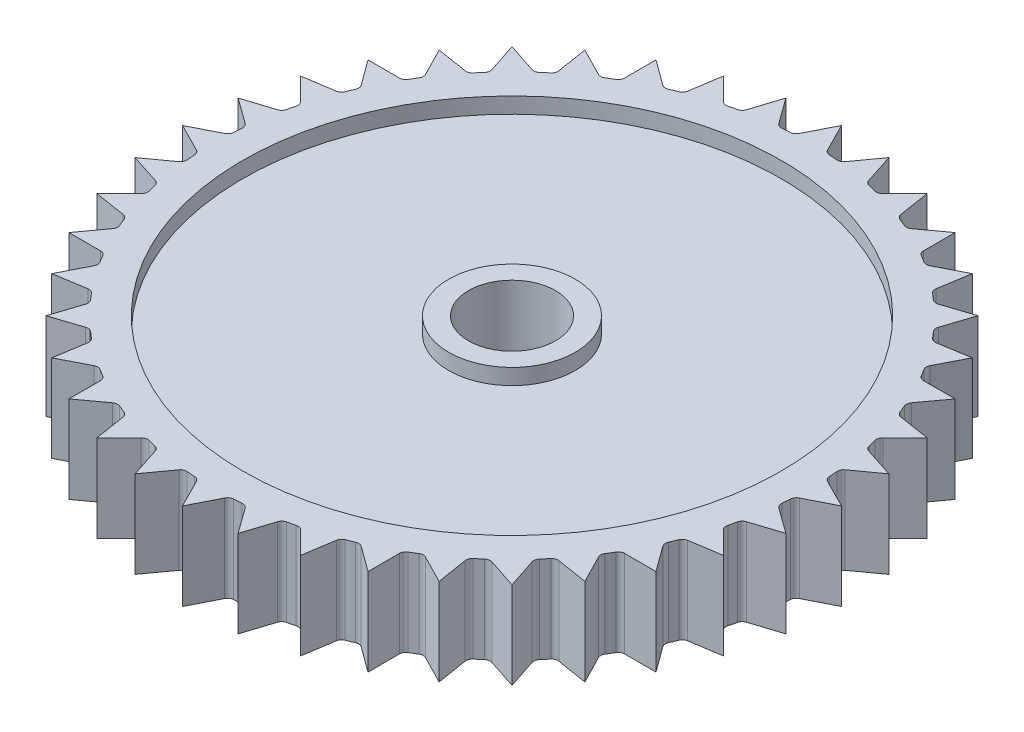
from build123d import *

# Parameters (mm, degrees)
BOSS_EXTRUDE1_DEPTH = 5.5
SKETCH2_R           = 2.75
CUT_EXTRUDE1_DEPTH  = 30.939308609
SKETCH2_3_R         = 17
SKETCH2_3_R_2       = 4
CUT_EXTRUDE2_DEPTH  = 1
CUT_EXTRUDE4_START  = -1
SKETCH4_R           = 17
SKETCH4_R_2         = 4
CUT_EXTRUDE4_DEPTH  = 1
BOSS_EXTRUDE2_DEPTH = 5.5


with BuildPart() as part:
    # Sketch1 → Boss-Extrude1 (new body)
    with BuildSketch(Plane(origin=(0, 0, 0), x_dir=(1, 0, 0), z_dir=(0, 1, 0))):
        with BuildLine():
            Line((0.896211504, 19.03861126), (0, 20.81))
            Line((0, 20.81), (-0.896211504, 19.03861126))
            ThreePointArc((-0.896211504, 19.03861126), (-1.032664638, 18.885431522), (-1.22710516, 18.820037538))
            ThreePointArc((-1.22710516, 18.820037538), (-1.479738545, 18.801860914), (-1.732105045, 18.780293185))
            ThreePointArc((-1.732105045, 18.780293185), (-1.934381554, 18.814464862), (-2.093117314, 18.94441273))
            Line((-2.093117314, 18.94441273), (-3.255401217, 20.553794368))
            Line((-3.255401217, 20.553794368), (-3.863472621, 18.664015995))
            ThreePointArc((-3.863472621, 18.664015995), (-3.9742832, 18.491376181), (-4.156099964, 18.396370106))
            ThreePointArc((-4.156099964, 18.396370106), (-4.402779562, 18.338896699), (-4.648665075, 18.278115686))
            ThreePointArc((-4.648665075, 18.278115686), (-4.853796853, 18.280223635), (-5.030906637, 18.383739885))
            Line((-5.030906637, 18.383739885), (-6.430643653, 19.791486104))
            Line((-6.430643653, 19.791486104), (-6.73560222, 17.829850715))
            ThreePointArc((-6.73560222, 17.829850715), (-6.81804172, 17.642001789), (-6.982757793, 17.519722989))
            ThreePointArc((-6.982757793, 17.519722989), (-7.217409534, 17.424367983), (-7.450759543, 17.325870317))
            ThreePointArc((-7.450759543, 17.325870317), (-7.653695565, 17.295862633), (-7.844818343, 17.370398353))
            Line((-7.844818343, 17.370398353), (-9.4475423, 18.541845768))
            Line((-9.4475423, 18.541845768), (-9.441878938, 16.556655335))
            ThreePointArc((-9.441878938, 16.556655335), (-9.493917424, 16.358222763), (-9.63747695, 16.211682147))
            ThreePointArc((-9.63747695, 16.211682147), (-9.854322931, 16.0807935), (-10.069391584, 15.947004519))
            ThreePointArc((-10.069391584, 15.947004519), (-10.26513489, 15.885620092), (-10.465564585, 15.929339964))
            Line((-10.465564585, 15.929339964), (-12.2318111, 16.835643653))
            Line((-12.2318111, 16.835643653), (-11.91566526, 14.875780153))
            ThreePointArc((-11.91566526, 14.875780153), (-11.936021374, 14.671650003), (-12.054889441, 14.504455887))
            ThreePointArc((-12.054889441, 14.504455887), (-12.248590192, 14.341256511), (-12.440081785, 14.175470545))
            ThreePointArc((-12.440081785, 14.175470545), (-12.623812527, 14.084220863), (-12.828613894, 14.096048358))
            Line((-12.828613894, 14.096048358), (-14.714892116, 14.714892116))
            Line((-14.714892116, 14.714892116), (-14.096048358, 12.828613894))
            ThreePointArc((-14.096048358, 12.828613894), (-14.084220863, 12.623812527), (-14.175470545, 12.440081785))
            ThreePointArc((-14.175470545, 12.440081785), (-14.341256511, 12.248590192), (-14.504455887, 12.054889441))
            ThreePointArc((-14.504455887, 12.054889441), (-14.671650003, 11.936021374), (-14.875780153, 11.91566526))
            Line((-14.875780153, 11.91566526), (-16.835643653, 12.2318111))
            Line((-16.835643653, 12.2318111), (-15.929339964, 10.465564585))
            ThreePointArc((-15.929339964, 10.465564585), (-15.885620092, 10.26513489), (-15.947004519, 10.069391584))
            ThreePointArc((-15.947004519, 10.069391584), (-16.0807935, 9.854322931), (-16.211682147, 9.63747695))
            ThreePointArc((-16.211682147, 9.63747695), (-16.358222763, 9.493917424), (-16.556655335, 9.441878938))
            Line((-16.556655335, 9.441878938), (-18.541845768, 9.4475423))
            Line((-18.541845768, 9.4475423), (-17.370398353, 7.844818343))
            ThreePointArc((-17.370398353, 7.844818343), (-17.295862633, 7.653695565), (-17.325870317, 7.450759543))
            ThreePointArc((-17.325870317, 7.450759543), (-17.424367983, 7.217409534), (-17.519722989, 6.982757793))
            ThreePointArc((-17.519722989, 6.982757793), (-17.642001789, 6.81804172), (-17.829850715, 6.73560222))
            Line((-17.829850715, 6.73560222), (-19.791486104, 6.430643653))
            Line((-19.791486104, 6.430643653), (-18.383739885, 5.030906637))
            ThreePointArc((-18.383739885, 5.030906637), (-18.280223635, 4.853796853), (-18.278115686, 4.648665075))
            ThreePointArc((-18.278115686, 4.648665075), (-18.338896699, 4.402779562), (-18.396370106, 4.156099964))
            ThreePointArc((-18.396370106, 4.156099964), (-18.491376181, 3.9742832), (-18.664015995, 3.863472621))
            Line((-18.664015995, 3.863472621), (-20.553794368, 3.255401217))
            Line((-20.553794368, 3.255401217), (-18.94441273, 2.093117314))
            ThreePointArc((-18.94441273, 2.093117314), (-18.814464862, 1.934381554), (-18.780293185, 1.732105045))
            ThreePointArc((-18.780293185, 1.732105045), (-18.801860914, 1.479738545), (-18.820037538, 1.22710516))
            ThreePointArc((-18.820037538, 1.22710516), (-18.885431522, 1.032664638), (-19.03861126, 0.896211504))
            Line((-19.03861126, 0.896211504), (-20.81, 0))
            Line((-20.81, 0), (-19.03861126, -0.896211504))
            ThreePointArc((-19.03861126, -0.896211504), (-18.885431522, -1.032664638), (-18.820037538, -1.22710516))
            ThreePointArc((-18.820037538, -1.22710516), (-18.801860914, -1.479738545), (-18.780293185, -1.732105045))
            ThreePointArc((-18.780293185, -1.732105045), (-18.814464862, -1.934381554), (-18.94441273, -2.093117314))
            Line((-18.94441273, -2.093117314), (-20.553794368, -3.255401217))
            Line((-20.553794368, -3.255401217), (-18.664015995, -3.863472621))
            ThreePointArc((-18.664015995, -3.863472621), (-18.491376181, -3.9742832), (-18.396370106, -4.156099964))
            ThreePointArc((-18.396370106, -4.156099964), (-18.338896699, -4.402779562), (-18.278115686, -4.648665075))
            ThreePointArc((-18.278115686, -4.648665075), (-18.280223635, -4.853796853), (-18.383739885, -5.030906637))
            Line((-18.383739885, -5.030906637), (-19.791486104, -6.430643653))
            Line((-19.791486104, -6.430643653), (-17.829850715, -6.73560222))
            ThreePointArc((-17.829850715, -6.73560222), (-17.642001789, -6.81804172), (-17.519722989, -6.982757793))
            ThreePointArc((-17.519722989, -6.982757793), (-17.424367983, -7.217409534), (-17.325870317, -7.450759543))
            ThreePointArc((-17.325870317, -7.450759543), (-17.295862633, -7.653695565), (-17.370398353, -7.844818343))
            Line((-17.370398353, -7.844818343), (-18.541845768, -9.4475423))
            Line((-18.541845768, -9.4475423), (-16.556655335, -9.441878938))
            ThreePointArc((-16.556655335, -9.441878938), (-16.358222763, -9.493917424), (-16.211682147, -9.63747695))
            ThreePointArc((-16.211682147, -9.63747695), (-16.0807935, -9.854322931), (-15.947004519, -10.069391584))
            ThreePointArc((-15.947004519, -10.069391584), (-15.885620092, -10.26513489), (-15.929339964, -10.465564585))
            Line((-15.929339964, -10.465564585), (-16.835643653, -12.2318111))
            Line((-16.835643653, -12.2318111), (-14.875780153, -11.91566526))
            ThreePointArc((-14.875780153, -11.91566526), (-14.671650003, -11.936021374), (-14.504455887, -12.054889441))
            ThreePointArc((-14.504455887, -12.054889441), (-14.341256511, -12.248590192), (-14.175470545, -12.440081785))
            ThreePointArc((-14.175470545, -12.440081785), (-14.084220863, -12.623812527), (-14.096048358, -12.828613894))
            Line((-14.096048358, -12.828613894), (-14.714892116, -14.714892116))
            Line((-14.714892116, -14.714892116), (-12.828613894, -14.096048358))
            ThreePointArc((-12.828613894, -14.096048358), (-12.623812527, -14.084220863), (-12.440081785, -14.175470545))
            ThreePointArc((-12.440081785, -14.175470545), (-12.248590192, -14.341256511), (-12.054889441, -14.504455887))
            ThreePointArc((-12.054889441, -14.504455887), (-11.936021374, -14.671650003), (-11.91566526, -14.875780153))
            Line((-11.91566526, -14.875780153), (-12.2318111, -16.835643653))
            Line((-12.2318111, -16.835643653), (-10.465564585, -15.929339964))
            ThreePointArc((-10.465564585, -15.929339964), (-10.26513489, -15.885620092), (-10.069391584, -15.947004519))
            ThreePointArc((-10.069391584, -15.947004519), (-9.854322931, -16.0807935), (-9.63747695, -16.211682147))
            ThreePointArc((-9.63747695, -16.211682147), (-9.493917424, -16.358222763), (-9.441878938, -16.556655335))
            Line((-9.441878938, -16.556655335), (-9.4475423, -18.541845768))
            Line((-9.4475423, -18.541845768), (-7.844818343, -17.370398353))
            ThreePointArc((-7.844818343, -17.370398353), (-7.653695565, -17.295862633), (-7.450759543, -17.325870317))
            ThreePointArc((-7.450759543, -17.325870317), (-7.217409534, -17.424367983), (-6.982757793, -17.519722989))
            ThreePointArc((-6.982757793, -17.519722989), (-6.81804172, -17.642001789), (-6.73560222, -17.829850715))
            Line((-6.73560222, -17.829850715), (-6.430643653, -19.791486104))
            Line((-6.430643653, -19.791486104), (-5.030906637, -18.383739885))
            ThreePointArc((-5.030906637, -18.383739885), (-4.853796853, -18.280223635), (-4.648665075, -18.278115686))
            ThreePointArc((-4.648665075, -18.278115686), (-4.402779562, -18.338896699), (-4.156099964, -18.396370106))
            ThreePointArc((-4.156099964, -18.396370106), (-3.9742832, -18.491376181), (-3.863472621, -18.664015995))
            Line((-3.863472621, -18.664015995), (-3.255401217, -20.553794368))
            Line((-3.255401217, -20.553794368), (-2.093117314, -18.94441273))
            ThreePointArc((-2.093117314, -18.94441273), (-1.934381554, -18.814464862), (-1.732105045, -18.780293185))
            ThreePointArc((-1.732105045, -18.780293185), (-1.479738545, -18.801860914), (-1.22710516, -18.820037538))
            ThreePointArc((-1.22710516, -18.820037538), (-1.032664638, -18.885431522), (-0.896211504, -19.03861126))
            Line((-0.896211504, -19.03861126), (0, -20.81))
            Line((0, -20.81), (0.896211504, -19.03861126))
            ThreePointArc((0.896211504, -19.03861126), (1.032664638, -18.885431522), (1.22710516, -18.820037538))
            ThreePointArc((1.22710516, -18.820037538), (1.479738545, -18.801860914), (1.732105045, -18.780293185))
            ThreePointArc((1.732105045, -18.780293185), (1.934381554, -18.814464862), (2.093117314, -18.94441273))
            Line((2.093117314, -18.94441273), (3.255401217, -20.553794368))
            Line((3.255401217, -20.553794368), (3.863472621, -18.664015995))
            ThreePointArc((3.863472621, -18.664015995), (3.9742832, -18.491376181), (4.156099964, -18.396370106))
            ThreePointArc((4.156099964, -18.396370106), (4.402779562, -18.338896699), (4.648665075, -18.278115686))
            ThreePointArc((4.648665075, -18.278115686), (4.853796853, -18.280223635), (5.030906637, -18.383739885))
            Line((5.030906637, -18.383739885), (6.430643653, -19.791486104))
            Line((6.430643653, -19.791486104), (6.73560222, -17.829850715))
            ThreePointArc((6.73560222, -17.829850715), (6.81804172, -17.642001789), (6.982757793, -17.519722989))
            ThreePointArc((6.982757793, -17.519722989), (7.217409534, -17.424367983), (7.450759543, -17.325870317))
            ThreePointArc((7.450759543, -17.325870317), (7.653695565, -17.295862633), (7.844818343, -17.370398353))
            Line((7.844818343, -17.370398353), (9.4475423, -18.541845768))
            Line((9.4475423, -18.541845768), (9.441878938, -16.556655335))
            ThreePointArc((9.441878938, -16.556655335), (9.493917424, -16.358222763), (9.63747695, -16.211682147))
            ThreePointArc((9.63747695, -16.211682147), (9.854322931, -16.0807935), (10.069391584, -15.947004519))
            ThreePointArc((10.069391584, -15.947004519), (10.26513489, -15.885620092), (10.465564585, -15.929339964))
            Line((10.465564585, -15.929339964), (12.2318111, -16.835643653))
            Line((12.2318111, -16.835643653), (11.91566526, -14.875780153))
            ThreePointArc((11.91566526, -14.875780153), (11.936021374, -14.671650003), (12.054889441, -14.504455887))
            ThreePointArc((12.054889441, -14.504455887), (12.248590192, -14.341256511), (12.440081785, -14.175470545))
            ThreePointArc((12.440081785, -14.175470545), (12.623812527, -14.084220863), (12.828613894, -14.096048358))
            Line((12.828613894, -14.096048358), (14.714892116, -14.714892116))
            Line((14.714892116, -14.714892116), (14.096048358, -12.828613894))
            ThreePointArc((14.096048358, -12.828613894), (14.084220863, -12.623812527), (14.175470545, -12.440081785))
            ThreePointArc((14.175470545, -12.440081785), (14.341256511, -12.248590192), (14.504455887, -12.054889441))
            ThreePointArc((14.504455887, -12.054889441), (14.671650003, -11.936021374), (14.875780153, -11.91566526))
            Line((14.875780153, -11.91566526), (16.835643653, -12.2318111))
            Line((16.835643653, -12.2318111), (15.929339964, -10.465564585))
            ThreePointArc((15.929339964, -10.465564585), (15.885620092, -10.26513489), (15.947004519, -10.069391584))
            ThreePointArc((15.947004519, -10.069391584), (16.0807935, -9.854322931), (16.211682147, -9.63747695))
            ThreePointArc((16.211682147, -9.63747695), (16.358222763, -9.493917424), (16.556655335, -9.441878938))
            Line((16.556655335, -9.441878938), (18.541845768, -9.4475423))
            Line((18.541845768, -9.4475423), (17.370398353, -7.844818343))
            ThreePointArc((17.370398353, -7.844818343), (17.295862633, -7.653695565), (17.325870317, -7.450759543))
            ThreePointArc((17.325870317, -7.450759543), (17.424367983, -7.217409534), (17.519722989, -6.982757793))
            ThreePointArc((17.519722989, -6.982757793), (17.642001789, -6.81804172), (17.829850715, -6.73560222))
            Line((17.829850715, -6.73560222), (19.791486104, -6.430643653))
            Line((19.791486104, -6.430643653), (18.383739885, -5.030906637))
            ThreePointArc((18.383739885, -5.030906637), (18.280223635, -4.853796853), (18.278115686, -4.648665075))
            ThreePointArc((18.278115686, -4.648665075), (18.338896699, -4.402779562), (18.396370106, -4.156099964))
            ThreePointArc((18.396370106, -4.156099964), (18.627802104, -2.950354011), (18.780293185, -1.732105045))
            ThreePointArc((18.780293185, -1.732105045), (18.801860914, -1.479738545), (18.820037538, -1.22710516))
            ThreePointArc((18.820037538, -1.22710516), (18.885431522, -1.032664638), (19.03861126, -0.896211504))
            Line((19.03861126, -0.896211504), (20.81, 0))
            Line((20.81, 0), (19.03861126, 0.896211504))
            ThreePointArc((19.03861126, 0.896211504), (18.885431522, 1.032664638), (18.820037538, 1.22710516))
            ThreePointArc((18.820037538, 1.22710516), (18.801860914, 1.479738545), (18.780293185, 1.732105045))
            ThreePointArc((18.780293185, 1.732105045), (18.814464862, 1.934381554), (18.94441273, 2.093117314))
            Line((18.94441273, 2.093117314), (20.553794368, 3.255401217))
            Line((20.553794368, 3.255401217), (18.664015995, 3.863472621))
            ThreePointArc((18.664015995, 3.863472621), (18.491376181, 3.9742832), (18.396370106, 4.156099964))
            ThreePointArc((18.396370106, 4.156099964), (18.338896699, 4.402779562), (18.278115686, 4.648665075))
            ThreePointArc((18.278115686, 4.648665075), (18.280223635, 4.853796853), (18.383739885, 5.030906637))
            Line((18.383739885, 5.030906637), (19.791486104, 6.430643653))
            Line((19.791486104, 6.430643653), (17.829850715, 6.73560222))
            ThreePointArc((17.829850715, 6.73560222), (17.642001789, 6.81804172), (17.519722989, 6.982757793))
            ThreePointArc((17.519722989, 6.982757793), (17.424367983, 7.217409534), (17.325870317, 7.450759543))
            ThreePointArc((17.325870317, 7.450759543), (17.295862633, 7.653695565), (17.370398353, 7.844818343))
            Line((17.370398353, 7.844818343), (18.541845768, 9.4475423))
            Line((18.541845768, 9.4475423), (16.556655335, 9.441878938))
            ThreePointArc((16.556655335, 9.441878938), (16.358222763, 9.493917424), (16.211682147, 9.63747695))
            ThreePointArc((16.211682147, 9.63747695), (16.0807935, 9.854322931), (15.947004519, 10.069391584))
            ThreePointArc((15.947004519, 10.069391584), (15.885620092, 10.26513489), (15.929339964, 10.465564585))
            Line((15.929339964, 10.465564585), (16.835643653, 12.2318111))
            Line((16.835643653, 12.2318111), (14.875780153, 11.91566526))
            ThreePointArc((14.875780153, 11.91566526), (14.671650003, 11.936021374), (14.504455887, 12.054889441))
            ThreePointArc((14.504455887, 12.054889441), (14.341256511, 12.248590192), (14.175470545, 12.440081785))
            ThreePointArc((14.175470545, 12.440081785), (14.084220863, 12.623812527), (14.096048358, 12.828613894))
            Line((14.096048358, 12.828613894), (14.714892116, 14.714892116))
            Line((14.714892116, 14.714892116), (12.828613894, 14.096048358))
            ThreePointArc((12.828613894, 14.096048358), (12.623812527, 14.084220863), (12.440081785, 14.175470545))
            ThreePointArc((12.440081785, 14.175470545), (12.248590192, 14.341256511), (12.054889441, 14.504455887))
            ThreePointArc((12.054889441, 14.504455887), (11.936021374, 14.671650003), (11.91566526, 14.875780153))
            Line((11.91566526, 14.875780153), (12.2318111, 16.835643653))
            Line((12.2318111, 16.835643653), (10.465564585, 15.929339964))
            ThreePointArc((10.465564585, 15.929339964), (10.26513489, 15.885620092), (10.069391584, 15.947004519))
            ThreePointArc((10.069391584, 15.947004519), (9.854322931, 16.0807935), (9.63747695, 16.211682147))
            ThreePointArc((9.63747695, 16.211682147), (9.493917424, 16.358222763), (9.441878938, 16.556655335))
            Line((9.441878938, 16.556655335), (9.4475423, 18.541845768))
            Line((9.4475423, 18.541845768), (7.844818343, 17.370398353))
            ThreePointArc((7.844818343, 17.370398353), (7.653695565, 17.295862633), (7.450759543, 17.325870317))
            ThreePointArc((7.450759543, 17.325870317), (7.217409534, 17.424367983), (6.982757793, 17.519722989))
            ThreePointArc((6.982757793, 17.519722989), (6.81804172, 17.642001789), (6.73560222, 17.829850715))
            Line((6.73560222, 17.829850715), (6.430643653, 19.791486104))
            Line((6.430643653, 19.791486104), (5.030906637, 18.383739885))
            ThreePointArc((5.030906637, 18.383739885), (4.853796853, 18.280223635), (4.648665075, 18.278115686))
            ThreePointArc((4.648665075, 18.278115686), (4.402779562, 18.338896699), (4.156099964, 18.396370106))
            ThreePointArc((4.156099964, 18.396370106), (3.9742832, 18.491376181), (3.863472621, 18.664015995))
            Line((3.863472621, 18.664015995), (3.255401217, 20.553794368))
            Line((3.255401217, 20.553794368), (2.093117314, 18.94441273))
            ThreePointArc((2.093117314, 18.94441273), (1.934381554, 18.814464862), (1.732105045, 18.780293185))
            ThreePointArc((1.732105045, 18.780293185), (1.479738545, 18.801860914), (1.22710516, 18.820037538))
            ThreePointArc((1.22710516, 18.820037538), (1.032664638, 18.885431522), (0.896211504, 19.03861126))
        make_face()
    extrude(amount=BOSS_EXTRUDE1_DEPTH)

    # Sketch2 → Cut-Extrude1 (cut, through all)
    with BuildSketch(Plane(origin=(0, 5.5, 0), x_dir=(1, 0, 0), z_dir=(0, 1, 0))):
        Circle(SKETCH2_R)
    extrude(amount=-CUT_EXTRUDE1_DEPTH, mode=Mode.SUBTRACT)

    # Sketch2_3 → Cut-Extrude2 (cut)
    with BuildSketch(Plane(origin=(0, 5.5, 0), x_dir=(1, 0, 0), z_dir=(0, 1, 0))):
        Circle(SKETCH2_3_R)
        Circle(SKETCH2_3_R_2, mode=Mode.SUBTRACT)
    extrude(amount=-CUT_EXTRUDE2_DEPTH, mode=Mode.SUBTRACT)

    # Sketch4 → Cut-Extrude4 (cut)
    with BuildSketch(Plane.XZ.offset(CUT_EXTRUDE4_START)):
        Circle(SKETCH4_R)
        Circle(SKETCH4_R_2, mode=Mode.SUBTRACT)
    extrude(amount=CUT_EXTRUDE4_DEPTH, mode=Mode.SUBTRACT)

    # Sketch1_3 → Boss-Extrude2 (add)
    with BuildSketch(Plane(origin=(0, 0, 0), x_dir=(1, 0, 0), z_dir=(0, 1, 0))):
        with BuildLine():
            ThreePointArc((18.94441273, -2.093117314), (18.814464862, -1.934381554), (18.780293185, -1.732105045))
            ThreePointArc((18.780293185, -1.732105045), (18.627802104, -2.950354011), (18.396370106, -4.156099964))
            ThreePointArc((18.396370106, -4.156099964), (18.491376181, -3.9742832), (18.664015995, -3.863472621))
            Line((18.664015995, -3.863472621), (20.553794368, -3.255401217))
            Line((20.553794368, -3.255401217), (18.94441273, -2.093117314))
        make_face()
    extrude(amount=BOSS_EXTRUDE2_DEPTH)


solid = part.part
